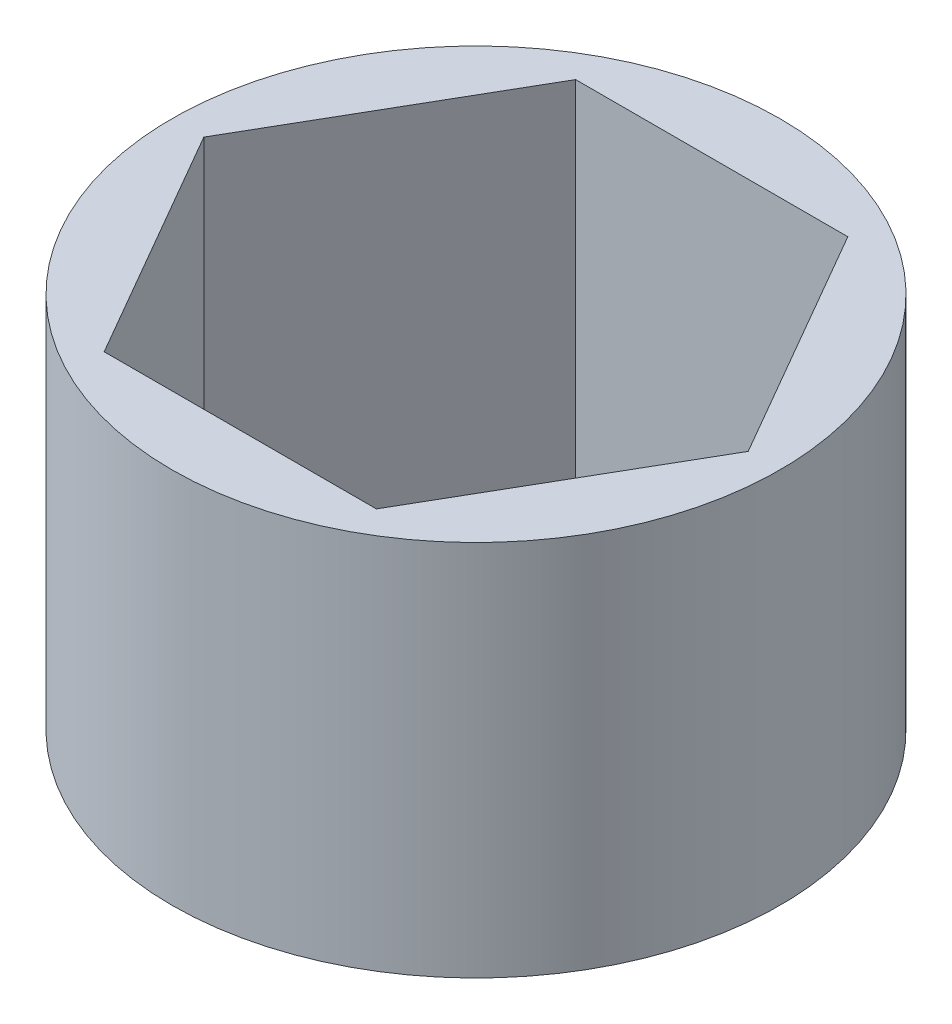
from build123d import *

# Parameters (mm, degrees)
SKETCH1_R           = 8.1915
BOSS_EXTRUDE1_DEPTH = 10.16


with BuildPart() as part:
    # Sketch1 → Boss-Extrude1 (new body)
    with BuildSketch(Plane(origin=(0, 0, 0), x_dir=(1, 0, 0), z_dir=(0, 1, 0))):
        Circle(SKETCH1_R)
        Polygon((3.666174209, 6.35), (-3.666174209, 6.35), (-7.332348419, 0), (-3.666174209, -6.35), (3.666174209, -6.35), (7.332348419, 0), align=None, mode=Mode.SUBTRACT)
    extrude(amount=BOSS_EXTRUDE1_DEPTH)


solid = part.part
